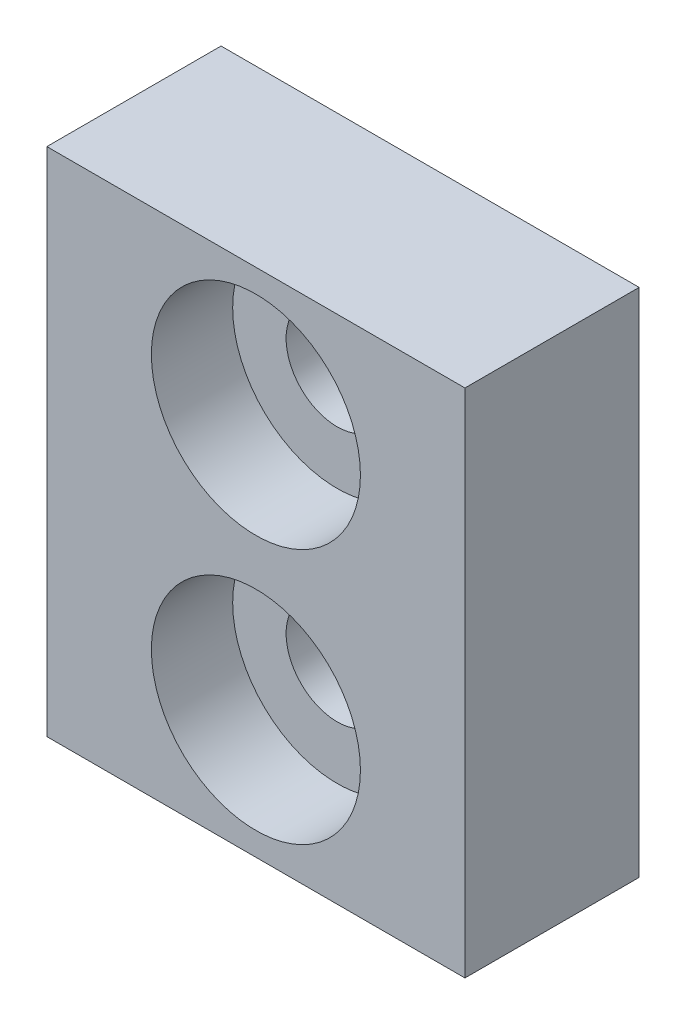
from build123d import *

# Parameters (mm, degrees)
SKIZZE1_W                       = 18
SKIZZE1_H                       = 11
SKIZZE1_R                       = 2.2
AUFSATZ_LINEAR_AUSTRAGEN1_DEPTH = 7.5
SKIZZE2_R                       = 4.5
SCHNITT_LINEAR_AUSTRAGEN1_DEPTH = 3.5


with BuildPart() as part:
    # Skizze1 → Aufsatz-Linear austragen1 (new body)
    with BuildSketch(Plane.XY):
        Rectangle(SKIZZE1_W, SKIZZE1_H)
        Circle(SKIZZE1_R, mode=Mode.SUBTRACT)
    extrude(amount=AUFSATZ_LINEAR_AUSTRAGEN1_DEPTH)

    # Skizze2 → Schnitt-Linear austragen1 (cut)
    with BuildSketch(Plane.XY.offset(7.5)):
        Circle(SKIZZE2_R)
    extrude(amount=-SCHNITT_LINEAR_AUSTRAGEN1_DEPTH, mode=Mode.SUBTRACT)

    # Spiegeln1: part across plane


with BuildPart() as part_1:
    add(part.part)
    add(part.part.mirror(Plane(origin=(-9, -5.5, 7.5), x_dir=(0, 0, 1), z_dir=(0, 1, 0))))


solid = part_1.part
